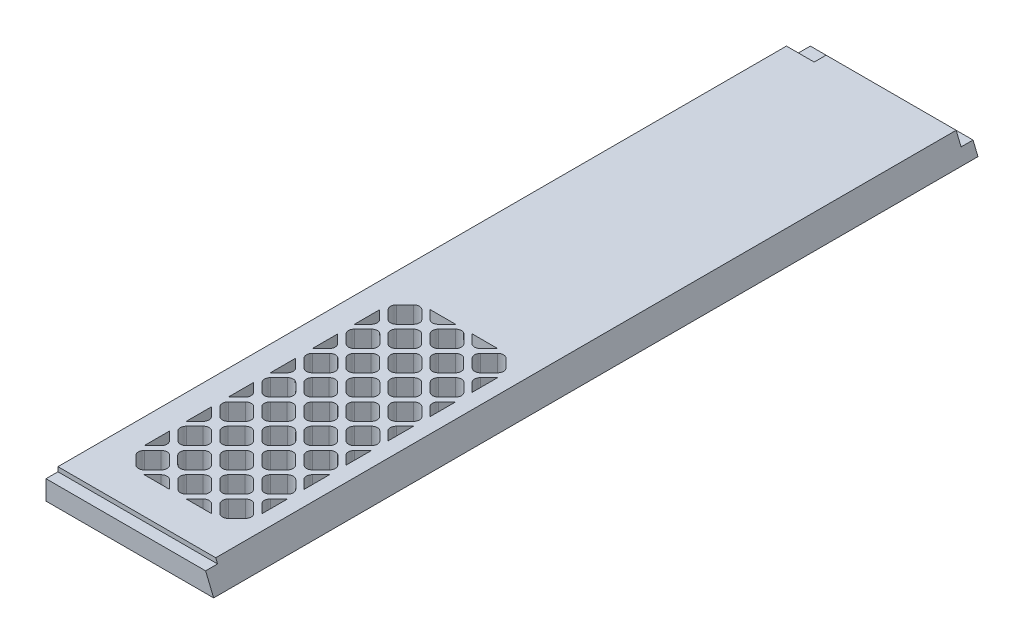
from build123d import *

# Parameters (mm, degrees)
BOSS_EXTRUDE1_DEPTH = 406.4
SKETCH2_W           = 89.154
SKETCH2_H           = 6.35
CUT_EXTRUDE1_DEPTH  = 2.3622
CUT_EXTRUDE3_DEPTH  = 13.7
CUT_EXTRUDE4_DEPTH  = 6.35


with BuildPart() as part:
    # Sketch1 → Boss-Extrude1 (new body)
    with BuildSketch(Plane.XY):
        Polygon((0, 0), (0, 12.7), (83.893487758, 12.7), (89.154, 0), align=None)
    extrude(amount=BOSS_EXTRUDE1_DEPTH)

    # Sketch2 → Cut-Extrude1 (cut)
    with BuildSketch(Plane.XZ.offset(-12.7)):
        with Locations((44.577, 403.225)):
            Rectangle(SKETCH2_W, SKETCH2_H)
    extrude(amount=CUT_EXTRUDE1_DEPTH, mode=Mode.SUBTRACT)

    # Sketch3 → Cut-Extrude3 (cut, through all)
    with BuildSketch(Plane.XZ):
        with BuildLine():
            ThreePointArc((19.97993597, 378.591192091), (22.225, 379.521128061), (24.47006403, 378.591192091))
            Line((24.47006403, 378.591192091), (28.960192091, 374.10106403))
            ThreePointArc((28.960192091, 374.10106403), (29.890128061, 371.856), (28.960192091, 369.61093597))
            Line((28.960192091, 369.61093597), (24.47006403, 365.120807909))
            ThreePointArc((24.47006403, 365.120807909), (22.225, 364.190871939), (19.97993597, 365.120807909))
            Line((19.97993597, 365.120807909), (15.489807909, 369.61093597))
            ThreePointArc((15.489807909, 369.61093597), (14.559871939, 371.856), (15.489807909, 374.10106403))
            Line((15.489807909, 374.10106403), (19.97993597, 378.591192091))
        make_face()
        with BuildLine():
            ThreePointArc((51.312192091, 374.10106403), (52.242128061, 371.856), (51.312192091, 369.61093597))
            Line((51.312192091, 369.61093597), (46.82206403, 365.120807909))
            ThreePointArc((46.82206403, 365.120807909), (44.577, 364.190871939), (42.33193597, 365.120807909))
            Line((42.33193597, 365.120807909), (37.841807909, 369.61093597))
            ThreePointArc((37.841807909, 369.61093597), (36.911871939, 371.856), (37.841807909, 374.10106403))
            Line((37.841807909, 374.10106403), (42.33193597, 378.591192091))
            ThreePointArc((42.33193597, 378.591192091), (44.577, 379.521128061), (46.82206403, 378.591192091))
            Line((46.82206403, 378.591192091), (51.312192091, 374.10106403))
        make_face()
        with BuildLine():
            ThreePointArc((73.664192091, 374.10106403), (74.594128061, 371.856), (73.664192091, 369.61093597))
            Line((73.664192091, 369.61093597), (69.17406403, 365.120807909))
            ThreePointArc((69.17406403, 365.120807909), (66.929, 364.190871939), (64.68393597, 365.120807909))
            Line((64.68393597, 365.120807909), (60.193807909, 369.61093597))
            ThreePointArc((60.193807909, 369.61093597), (59.263871939, 371.856), (60.193807909, 374.10106403))
            Line((60.193807909, 374.10106403), (64.68393597, 378.591192091))
            ThreePointArc((64.68393597, 378.591192091), (66.929, 379.521128061), (69.17406403, 378.591192091))
            Line((69.17406403, 378.591192091), (73.664192091, 374.10106403))
        make_face()
        with BuildLine():
            Line((40.086871939, 380.836256121), (26.616487758, 380.836256121))
            Line((26.616487758, 380.836256121), (31.106615818, 376.346128061))
            ThreePointArc((31.106615818, 376.346128061), (33.351679849, 375.416192091), (35.596743879, 376.346128061))
            Line((35.596743879, 376.346128061), (40.086871939, 380.836256121))
        make_face()
        with BuildLine():
            Line((17.734871939, 362.974384182), (13.244743879, 367.464512242))
            Line((13.244743879, 367.464512242), (13.244743879, 353.994128061))
            Line((13.244743879, 353.994128061), (17.734871939, 358.484256121))
            ThreePointArc((17.734871939, 358.484256121), (18.664807909, 360.729320151), (17.734871939, 362.974384182))
        make_face()
        with BuildLine():
            ThreePointArc((35.596743879, 353.994128061), (33.351679849, 353.064192091), (31.106615818, 353.994128061))
            Line((31.106615818, 353.994128061), (26.616487758, 358.484256121))
            ThreePointArc((26.616487758, 358.484256121), (25.686551788, 360.729320151), (26.616487758, 362.974384182))
            Line((26.616487758, 362.974384182), (31.106615818, 367.464512242))
            ThreePointArc((31.106615818, 367.464512242), (33.351679849, 368.394448212), (35.596743879, 367.464512242))
            Line((35.596743879, 367.464512242), (40.086871939, 362.974384182))
            ThreePointArc((40.086871939, 362.974384182), (41.016807909, 360.729320151), (40.086871939, 358.484256121))
            Line((40.086871939, 358.484256121), (35.596743879, 353.994128061))
        make_face()
        with BuildLine():
            ThreePointArc((57.948743879, 353.994128061), (55.703679849, 353.064192091), (53.458615818, 353.994128061))
            Line((53.458615818, 353.994128061), (48.968487758, 358.484256121))
            ThreePointArc((48.968487758, 358.484256121), (48.038551788, 360.729320151), (48.968487758, 362.974384182))
            Line((48.968487758, 362.974384182), (53.458615818, 367.464512242))
            ThreePointArc((53.458615818, 367.464512242), (55.703679849, 368.394448212), (57.948743879, 367.464512242))
            Line((57.948743879, 367.464512242), (62.438871939, 362.974384182))
            ThreePointArc((62.438871939, 362.974384182), (63.368807909, 360.729320151), (62.438871939, 358.484256121))
            Line((62.438871939, 358.484256121), (57.948743879, 353.994128061))
        make_face()
        with BuildLine():
            Line((75.909256121, 353.89964295), (75.909256121, 367.558997353))
            ThreePointArc((75.909256121, 367.558997353), (75.859427805, 367.51228531), (75.810615818, 367.464512242))
            Line((75.810615818, 367.464512242), (71.320487758, 362.974384182))
            ThreePointArc((71.320487758, 362.974384182), (70.390551788, 360.729320151), (71.320487758, 358.484256121))
            Line((71.320487758, 358.484256121), (75.810615818, 353.994128061))
            ThreePointArc((75.810615818, 353.994128061), (75.859427805, 353.946354993), (75.909256121, 353.89964295))
        make_face()
        with BuildLine():
            ThreePointArc((28.960192091, 351.74906403), (29.890128061, 349.504), (28.960192091, 347.25893597))
            Line((28.960192091, 347.25893597), (24.47006403, 342.768807909))
            ThreePointArc((24.47006403, 342.768807909), (22.225, 341.838871939), (19.97993597, 342.768807909))
            Line((19.97993597, 342.768807909), (15.489807909, 347.25893597))
            ThreePointArc((15.489807909, 347.25893597), (14.559871939, 349.504), (15.489807909, 351.74906403))
            Line((15.489807909, 351.74906403), (19.97993597, 356.239192091))
            ThreePointArc((19.97993597, 356.239192091), (22.225, 357.169128061), (24.47006403, 356.239192091))
            Line((24.47006403, 356.239192091), (28.960192091, 351.74906403))
        make_face()
        with BuildLine():
            ThreePointArc((46.82206403, 342.768807909), (44.577, 341.838871939), (42.33193597, 342.768807909))
            Line((42.33193597, 342.768807909), (37.841807909, 347.25893597))
            ThreePointArc((37.841807909, 347.25893597), (36.911871939, 349.504), (37.841807909, 351.74906403))
            Line((37.841807909, 351.74906403), (42.33193597, 356.239192091))
            ThreePointArc((42.33193597, 356.239192091), (44.577, 357.169128061), (46.82206403, 356.239192091))
            Line((46.82206403, 356.239192091), (51.312192091, 351.74906403))
            ThreePointArc((51.312192091, 351.74906403), (52.242128061, 349.504), (51.312192091, 347.25893597))
            Line((51.312192091, 347.25893597), (46.82206403, 342.768807909))
        make_face()
        with BuildLine():
            ThreePointArc((69.17406403, 342.768807909), (66.929, 341.838871939), (64.68393597, 342.768807909))
            Line((64.68393597, 342.768807909), (60.193807909, 347.25893597))
            ThreePointArc((60.193807909, 347.25893597), (59.263871939, 349.504), (60.193807909, 351.74906403))
            Line((60.193807909, 351.74906403), (64.68393597, 356.239192091))
            ThreePointArc((64.68393597, 356.239192091), (66.929, 357.169128061), (69.17406403, 356.239192091))
            Line((69.17406403, 356.239192091), (73.664192091, 351.74906403))
            ThreePointArc((73.664192091, 351.74906403), (74.594128061, 349.504), (73.664192091, 347.25893597))
            Line((73.664192091, 347.25893597), (69.17406403, 342.768807909))
        make_face()
        with BuildLine():
            Line((75.909256121, 331.54764295), (75.909256121, 345.206997353))
            ThreePointArc((75.909256121, 345.206997353), (75.859427805, 345.16028531), (75.810615818, 345.112512242))
            Line((75.810615818, 345.112512242), (71.320487758, 340.622384182))
            ThreePointArc((71.320487758, 340.622384182), (70.390551788, 338.377320151), (71.320487758, 336.132256121))
            Line((71.320487758, 336.132256121), (75.810615818, 331.642128061))
            ThreePointArc((75.810615818, 331.642128061), (75.859427805, 331.594354993), (75.909256121, 331.54764295))
        make_face()
        with BuildLine():
            ThreePointArc((57.948743879, 331.642128061), (55.703679849, 330.712192091), (53.458615818, 331.642128061))
            Line((53.458615818, 331.642128061), (48.968487758, 336.132256121))
            ThreePointArc((48.968487758, 336.132256121), (48.038551788, 338.377320151), (48.968487758, 340.622384182))
            Line((48.968487758, 340.622384182), (53.458615818, 345.112512242))
            ThreePointArc((53.458615818, 345.112512242), (55.703679849, 346.042448212), (57.948743879, 345.112512242))
            Line((57.948743879, 345.112512242), (62.438871939, 340.622384182))
            ThreePointArc((62.438871939, 340.622384182), (63.368807909, 338.377320151), (62.438871939, 336.132256121))
            Line((62.438871939, 336.132256121), (57.948743879, 331.642128061))
        make_face()
        with BuildLine():
            ThreePointArc((35.596743879, 331.642128061), (33.351679849, 330.712192091), (31.106615818, 331.642128061))
            Line((31.106615818, 331.642128061), (26.616487758, 336.132256121))
            ThreePointArc((26.616487758, 336.132256121), (25.686551788, 338.377320151), (26.616487758, 340.622384182))
            Line((26.616487758, 340.622384182), (31.106615818, 345.112512242))
            ThreePointArc((31.106615818, 345.112512242), (33.351679849, 346.042448212), (35.596743879, 345.112512242))
            Line((35.596743879, 345.112512242), (40.086871939, 340.622384182))
            ThreePointArc((40.086871939, 340.622384182), (41.016807909, 338.377320151), (40.086871939, 336.132256121))
            Line((40.086871939, 336.132256121), (35.596743879, 331.642128061))
        make_face()
        with BuildLine():
            Line((17.734871939, 340.622384182), (13.244743879, 345.112512242))
            Line((13.244743879, 345.112512242), (13.244743879, 331.642128061))
            Line((13.244743879, 331.642128061), (17.734871939, 336.132256121))
            ThreePointArc((17.734871939, 336.132256121), (18.664807909, 338.377320151), (17.734871939, 340.622384182))
        make_face()
        with BuildLine():
            ThreePointArc((28.960192091, 329.39706403), (29.890128061, 327.152), (28.960192091, 324.90693597))
            Line((28.960192091, 324.90693597), (24.47006403, 320.416807909))
            ThreePointArc((24.47006403, 320.416807909), (22.225, 319.486871939), (19.97993597, 320.416807909))
            Line((19.97993597, 320.416807909), (15.489807909, 324.90693597))
            ThreePointArc((15.489807909, 324.90693597), (14.559871939, 327.152), (15.489807909, 329.39706403))
            Line((15.489807909, 329.39706403), (19.97993597, 333.887192091))
            ThreePointArc((19.97993597, 333.887192091), (22.225, 334.817128061), (24.47006403, 333.887192091))
            Line((24.47006403, 333.887192091), (28.960192091, 329.39706403))
        make_face()
        with BuildLine():
            ThreePointArc((46.82206403, 320.416807909), (44.577, 319.486871939), (42.33193597, 320.416807909))
            Line((42.33193597, 320.416807909), (37.841807909, 324.90693597))
            ThreePointArc((37.841807909, 324.90693597), (36.911871939, 327.152), (37.841807909, 329.39706403))
            Line((37.841807909, 329.39706403), (42.33193597, 333.887192091))
            ThreePointArc((42.33193597, 333.887192091), (44.577, 334.817128061), (46.82206403, 333.887192091))
            Line((46.82206403, 333.887192091), (51.312192091, 329.39706403))
            ThreePointArc((51.312192091, 329.39706403), (52.242128061, 327.152), (51.312192091, 324.90693597))
            Line((51.312192091, 324.90693597), (46.82206403, 320.416807909))
        make_face()
        with BuildLine():
            ThreePointArc((69.17406403, 320.416807909), (66.929, 319.486871939), (64.68393597, 320.416807909))
            Line((64.68393597, 320.416807909), (60.193807909, 324.90693597))
            ThreePointArc((60.193807909, 324.90693597), (59.263871939, 327.152), (60.193807909, 329.39706403))
            Line((60.193807909, 329.39706403), (64.68393597, 333.887192091))
            ThreePointArc((64.68393597, 333.887192091), (66.929, 334.817128061), (69.17406403, 333.887192091))
            Line((69.17406403, 333.887192091), (73.664192091, 329.39706403))
            ThreePointArc((73.664192091, 329.39706403), (74.594128061, 327.152), (73.664192091, 324.90693597))
            Line((73.664192091, 324.90693597), (69.17406403, 320.416807909))
        make_face()
        with BuildLine():
            ThreePointArc((57.948743879, 309.290128061), (55.703679849, 308.360192091), (53.458615818, 309.290128061))
            Line((53.458615818, 309.290128061), (48.968487758, 313.780256121))
            ThreePointArc((48.968487758, 313.780256121), (48.038551788, 316.025320151), (48.968487758, 318.270384182))
            Line((48.968487758, 318.270384182), (53.458615818, 322.760512242))
            ThreePointArc((53.458615818, 322.760512242), (55.703679849, 323.690448212), (57.948743879, 322.760512242))
            Line((57.948743879, 322.760512242), (62.438871939, 318.270384182))
            ThreePointArc((62.438871939, 318.270384182), (63.368807909, 316.025320151), (62.438871939, 313.780256121))
            Line((62.438871939, 313.780256121), (57.948743879, 309.290128061))
        make_face()
        with BuildLine():
            Line((75.909256121, 309.19564295), (75.909256121, 322.854997353))
            ThreePointArc((75.909256121, 322.854997353), (75.859427805, 322.80828531), (75.810615818, 322.760512242))
            Line((75.810615818, 322.760512242), (71.320487758, 318.270384182))
            ThreePointArc((71.320487758, 318.270384182), (70.390551788, 316.025320151), (71.320487758, 313.780256121))
            Line((71.320487758, 313.780256121), (75.810615818, 309.290128061))
            ThreePointArc((75.810615818, 309.290128061), (75.859427805, 309.242354993), (75.909256121, 309.19564295))
        make_face()
        with BuildLine():
            Line((62.438871939, 380.836256121), (48.968487758, 380.836256121))
            Line((48.968487758, 380.836256121), (53.458615818, 376.346128061))
            ThreePointArc((53.458615818, 376.346128061), (55.703679849, 375.416192091), (57.948743879, 376.346128061))
            Line((57.948743879, 376.346128061), (62.438871939, 380.836256121))
        make_face()
        with BuildLine():
            ThreePointArc((35.596743879, 309.290128061), (33.351679849, 308.360192091), (31.106615818, 309.290128061))
            Line((31.106615818, 309.290128061), (26.616487758, 313.780256121))
            ThreePointArc((26.616487758, 313.780256121), (25.686551788, 316.025320151), (26.616487758, 318.270384182))
            Line((26.616487758, 318.270384182), (31.106615818, 322.760512242))
            ThreePointArc((31.106615818, 322.760512242), (33.351679849, 323.690448212), (35.596743879, 322.760512242))
            Line((35.596743879, 322.760512242), (40.086871939, 318.270384182))
            ThreePointArc((40.086871939, 318.270384182), (41.016807909, 316.025320151), (40.086871939, 313.780256121))
            Line((40.086871939, 313.780256121), (35.596743879, 309.290128061))
        make_face()
        with BuildLine():
            Line((17.734871939, 318.270384182), (13.244743879, 322.760512242))
            Line((13.244743879, 322.760512242), (13.244743879, 309.290128061))
            Line((13.244743879, 309.290128061), (17.734871939, 313.780256121))
            ThreePointArc((17.734871939, 313.780256121), (18.664807909, 316.025320151), (17.734871939, 318.270384182))
        make_face()
        with BuildLine():
            ThreePointArc((28.960192091, 307.04506403), (29.890128061, 304.8), (28.960192091, 302.55493597))
            Line((28.960192091, 302.55493597), (24.47006403, 298.064807909))
            ThreePointArc((24.47006403, 298.064807909), (22.225, 297.134871939), (19.97993597, 298.064807909))
            Line((19.97993597, 298.064807909), (15.489807909, 302.55493597))
            ThreePointArc((15.489807909, 302.55493597), (14.559871939, 304.8), (15.489807909, 307.04506403))
            Line((15.489807909, 307.04506403), (19.97993597, 311.535192091))
            ThreePointArc((19.97993597, 311.535192091), (22.225, 312.465128061), (24.47006403, 311.535192091))
            Line((24.47006403, 311.535192091), (28.960192091, 307.04506403))
        make_face()
        with BuildLine():
            ThreePointArc((46.82206403, 298.064807909), (44.577, 297.134871939), (42.33193597, 298.064807909))
            Line((42.33193597, 298.064807909), (37.841807909, 302.55493597))
            ThreePointArc((37.841807909, 302.55493597), (36.911871939, 304.8), (37.841807909, 307.04506403))
            Line((37.841807909, 307.04506403), (42.33193597, 311.535192091))
            ThreePointArc((42.33193597, 311.535192091), (44.577, 312.465128061), (46.82206403, 311.535192091))
            Line((46.82206403, 311.535192091), (51.312192091, 307.04506403))
            ThreePointArc((51.312192091, 307.04506403), (52.242128061, 304.8), (51.312192091, 302.55493597))
            Line((51.312192091, 302.55493597), (46.82206403, 298.064807909))
        make_face()
        with BuildLine():
            ThreePointArc((69.17406403, 298.064807909), (66.929, 297.134871939), (64.68393597, 298.064807909))
            Line((64.68393597, 298.064807909), (60.193807909, 302.55493597))
            ThreePointArc((60.193807909, 302.55493597), (59.263871939, 304.8), (60.193807909, 307.04506403))
            Line((60.193807909, 307.04506403), (64.68393597, 311.535192091))
            ThreePointArc((64.68393597, 311.535192091), (66.929, 312.465128061), (69.17406403, 311.535192091))
            Line((69.17406403, 311.535192091), (73.664192091, 307.04506403))
            ThreePointArc((73.664192091, 307.04506403), (74.594128061, 304.8), (73.664192091, 302.55493597))
            Line((73.664192091, 302.55493597), (69.17406403, 298.064807909))
        make_face()
        with BuildLine():
            Line((17.734871939, 295.918384182), (13.244743879, 300.408512242))
            Line((13.244743879, 300.408512242), (13.244743879, 286.938128061))
            Line((13.244743879, 286.938128061), (17.734871939, 291.428256121))
            ThreePointArc((17.734871939, 291.428256121), (18.664807909, 293.673320151), (17.734871939, 295.918384182))
        make_face()
        with BuildLine():
            ThreePointArc((28.960192091, 284.69306403), (29.890128061, 282.448), (28.960192091, 280.20293597))
            Line((28.960192091, 280.20293597), (24.47006403, 275.712807909))
            ThreePointArc((24.47006403, 275.712807909), (22.225, 274.782871939), (19.97993597, 275.712807909))
            Line((19.97993597, 275.712807909), (15.489807909, 280.20293597))
            ThreePointArc((15.489807909, 280.20293597), (14.559871939, 282.448), (15.489807909, 284.69306403))
            Line((15.489807909, 284.69306403), (19.97993597, 289.183192091))
            ThreePointArc((19.97993597, 289.183192091), (22.225, 290.113128061), (24.47006403, 289.183192091))
            Line((24.47006403, 289.183192091), (28.960192091, 284.69306403))
        make_face()
        with BuildLine():
            ThreePointArc((35.596743879, 286.938128061), (33.351679849, 286.008192091), (31.106615818, 286.938128061))
            Line((31.106615818, 286.938128061), (26.616487758, 291.428256121))
            ThreePointArc((26.616487758, 291.428256121), (25.686551788, 293.673320151), (26.616487758, 295.918384182))
            Line((26.616487758, 295.918384182), (31.106615818, 300.408512242))
            ThreePointArc((31.106615818, 300.408512242), (33.351679849, 301.338448212), (35.596743879, 300.408512242))
            Line((35.596743879, 300.408512242), (40.086871939, 295.918384182))
            ThreePointArc((40.086871939, 295.918384182), (41.016807909, 293.673320151), (40.086871939, 291.428256121))
            Line((40.086871939, 291.428256121), (35.596743879, 286.938128061))
        make_face()
        with BuildLine():
            ThreePointArc((46.82206403, 275.712807909), (44.577, 274.782871939), (42.33193597, 275.712807909))
            Line((42.33193597, 275.712807909), (37.841807909, 280.20293597))
            ThreePointArc((37.841807909, 280.20293597), (36.911871939, 282.448), (37.841807909, 284.69306403))
            Line((37.841807909, 284.69306403), (42.33193597, 289.183192091))
            ThreePointArc((42.33193597, 289.183192091), (44.577, 290.113128061), (46.82206403, 289.183192091))
            Line((46.82206403, 289.183192091), (51.312192091, 284.69306403))
            ThreePointArc((51.312192091, 284.69306403), (52.242128061, 282.448), (51.312192091, 280.20293597))
            Line((51.312192091, 280.20293597), (46.82206403, 275.712807909))
        make_face()
        with BuildLine():
            ThreePointArc((57.948743879, 286.938128061), (55.703679849, 286.008192091), (53.458615818, 286.938128061))
            Line((53.458615818, 286.938128061), (48.968487758, 291.428256121))
            ThreePointArc((48.968487758, 291.428256121), (48.038551788, 293.673320151), (48.968487758, 295.918384182))
            Line((48.968487758, 295.918384182), (53.458615818, 300.408512242))
            ThreePointArc((53.458615818, 300.408512242), (55.703679849, 301.338448212), (57.948743879, 300.408512242))
            Line((57.948743879, 300.408512242), (62.438871939, 295.918384182))
            ThreePointArc((62.438871939, 295.918384182), (63.368807909, 293.673320151), (62.438871939, 291.428256121))
            Line((62.438871939, 291.428256121), (57.948743879, 286.938128061))
        make_face()
        with BuildLine():
            Line((75.909256121, 286.84364295), (75.909256121, 300.502997353))
            ThreePointArc((75.909256121, 300.502997353), (75.859427805, 300.45628531), (75.810615818, 300.408512242))
            Line((75.810615818, 300.408512242), (71.320487758, 295.918384182))
            ThreePointArc((71.320487758, 295.918384182), (70.390551788, 293.673320151), (71.320487758, 291.428256121))
            Line((71.320487758, 291.428256121), (75.810615818, 286.938128061))
            ThreePointArc((75.810615818, 286.938128061), (75.859427805, 286.890354993), (75.909256121, 286.84364295))
        make_face()
        with BuildLine():
            ThreePointArc((69.17406403, 275.712807909), (66.929, 274.782871939), (64.68393597, 275.712807909))
            Line((64.68393597, 275.712807909), (60.193807909, 280.20293597))
            ThreePointArc((60.193807909, 280.20293597), (59.263871939, 282.448), (60.193807909, 284.69306403))
            Line((60.193807909, 284.69306403), (64.68393597, 289.183192091))
            ThreePointArc((64.68393597, 289.183192091), (66.929, 290.113128061), (69.17406403, 289.183192091))
            Line((69.17406403, 289.183192091), (73.664192091, 284.69306403))
            ThreePointArc((73.664192091, 284.69306403), (74.594128061, 282.448), (73.664192091, 280.20293597))
            Line((73.664192091, 280.20293597), (69.17406403, 275.712807909))
        make_face()
        with BuildLine():
            Line((17.734871939, 273.566384182), (13.244743879, 278.056512242))
            Line((13.244743879, 278.056512242), (13.244743879, 264.586128061))
            Line((13.244743879, 264.586128061), (17.734871939, 269.076256121))
            ThreePointArc((17.734871939, 269.076256121), (18.664807909, 271.321320151), (17.734871939, 273.566384182))
        make_face()
        with BuildLine():
            ThreePointArc((35.596743879, 264.586128061), (33.351679849, 263.656192091), (31.106615818, 264.586128061))
            Line((31.106615818, 264.586128061), (26.616487758, 269.076256121))
            ThreePointArc((26.616487758, 269.076256121), (25.686551788, 271.321320151), (26.616487758, 273.566384182))
            Line((26.616487758, 273.566384182), (31.106615818, 278.056512242))
            ThreePointArc((31.106615818, 278.056512242), (33.351679849, 278.986448212), (35.596743879, 278.056512242))
            Line((35.596743879, 278.056512242), (40.086871939, 273.566384182))
            ThreePointArc((40.086871939, 273.566384182), (41.016807909, 271.321320151), (40.086871939, 269.076256121))
            Line((40.086871939, 269.076256121), (35.596743879, 264.586128061))
        make_face()
        with BuildLine():
            ThreePointArc((57.948743879, 264.586128061), (55.703679849, 263.656192091), (53.458615818, 264.586128061))
            Line((53.458615818, 264.586128061), (48.968487758, 269.076256121))
            ThreePointArc((48.968487758, 269.076256121), (48.038551788, 271.321320151), (48.968487758, 273.566384182))
            Line((48.968487758, 273.566384182), (53.458615818, 278.056512242))
            ThreePointArc((53.458615818, 278.056512242), (55.703679849, 278.986448212), (57.948743879, 278.056512242))
            Line((57.948743879, 278.056512242), (62.438871939, 273.566384182))
            ThreePointArc((62.438871939, 273.566384182), (63.368807909, 271.321320151), (62.438871939, 269.076256121))
            Line((62.438871939, 269.076256121), (57.948743879, 264.586128061))
        make_face()
        with BuildLine():
            Line((75.909256121, 264.49164295), (75.909256121, 278.150997353))
            ThreePointArc((75.909256121, 278.150997353), (75.859427805, 278.10428531), (75.810615818, 278.056512242))
            Line((75.810615818, 278.056512242), (71.320487758, 273.566384182))
            ThreePointArc((71.320487758, 273.566384182), (70.390551788, 271.321320151), (71.320487758, 269.076256121))
            Line((71.320487758, 269.076256121), (75.810615818, 264.586128061))
            ThreePointArc((75.810615818, 264.586128061), (75.859427805, 264.538354993), (75.909256121, 264.49164295))
        make_face()
        with BuildLine():
            ThreePointArc((69.17406403, 253.360807909), (66.929, 252.430871939), (64.68393597, 253.360807909))
            Line((64.68393597, 253.360807909), (60.193807909, 257.85093597))
            ThreePointArc((60.193807909, 257.85093597), (59.263871939, 260.096), (60.193807909, 262.34106403))
            Line((60.193807909, 262.34106403), (64.68393597, 266.831192091))
            ThreePointArc((64.68393597, 266.831192091), (66.929, 267.761128061), (69.17406403, 266.831192091))
            Line((69.17406403, 266.831192091), (73.664192091, 262.34106403))
            ThreePointArc((73.664192091, 262.34106403), (74.594128061, 260.096), (73.664192091, 257.85093597))
            Line((73.664192091, 257.85093597), (69.17406403, 253.360807909))
        make_face()
        with BuildLine():
            ThreePointArc((46.82206403, 253.360807909), (44.577, 252.430871939), (42.33193597, 253.360807909))
            Line((42.33193597, 253.360807909), (37.841807909, 257.85093597))
            ThreePointArc((37.841807909, 257.85093597), (36.911871939, 260.096), (37.841807909, 262.34106403))
            Line((37.841807909, 262.34106403), (42.33193597, 266.831192091))
            ThreePointArc((42.33193597, 266.831192091), (44.577, 267.761128061), (46.82206403, 266.831192091))
            Line((46.82206403, 266.831192091), (51.312192091, 262.34106403))
            ThreePointArc((51.312192091, 262.34106403), (52.242128061, 260.096), (51.312192091, 257.85093597))
            Line((51.312192091, 257.85093597), (46.82206403, 253.360807909))
        make_face()
        with BuildLine():
            ThreePointArc((28.960192091, 262.34106403), (29.890128061, 260.096), (28.960192091, 257.85093597))
            Line((28.960192091, 257.85093597), (24.47006403, 253.360807909))
            ThreePointArc((24.47006403, 253.360807909), (22.225, 252.430871939), (19.97993597, 253.360807909))
            Line((19.97993597, 253.360807909), (15.489807909, 257.85093597))
            ThreePointArc((15.489807909, 257.85093597), (14.559871939, 260.096), (15.489807909, 262.34106403))
            Line((15.489807909, 262.34106403), (19.97993597, 266.831192091))
            ThreePointArc((19.97993597, 266.831192091), (22.225, 267.761128061), (24.47006403, 266.831192091))
            Line((24.47006403, 266.831192091), (28.960192091, 262.34106403))
        make_face()
        with BuildLine():
            Line((17.734871939, 251.214384182), (13.244743879, 255.704512242))
            Line((13.244743879, 255.704512242), (13.244743879, 242.234128061))
            Line((13.244743879, 242.234128061), (17.734871939, 246.724256121))
            ThreePointArc((17.734871939, 246.724256121), (18.664807909, 248.969320151), (17.734871939, 251.214384182))
        make_face()
        with BuildLine():
            ThreePointArc((28.960192091, 239.98906403), (29.890128061, 237.744), (28.960192091, 235.49893597))
            Line((28.960192091, 235.49893597), (24.47006403, 231.008807909))
            ThreePointArc((24.47006403, 231.008807909), (22.225, 230.078871939), (19.97993597, 231.008807909))
            Line((19.97993597, 231.008807909), (15.489807909, 235.49893597))
            ThreePointArc((15.489807909, 235.49893597), (14.559871939, 237.744), (15.489807909, 239.98906403))
            Line((15.489807909, 239.98906403), (19.97993597, 244.479192091))
            ThreePointArc((19.97993597, 244.479192091), (22.225, 245.409128061), (24.47006403, 244.479192091))
            Line((24.47006403, 244.479192091), (28.960192091, 239.98906403))
        make_face()
        with BuildLine():
            ThreePointArc((35.596743879, 242.234128061), (33.351679849, 241.304192091), (31.106615818, 242.234128061))
            Line((31.106615818, 242.234128061), (26.616487758, 246.724256121))
            ThreePointArc((26.616487758, 246.724256121), (25.686551788, 248.969320151), (26.616487758, 251.214384182))
            Line((26.616487758, 251.214384182), (31.106615818, 255.704512242))
            ThreePointArc((31.106615818, 255.704512242), (33.351679849, 256.634448212), (35.596743879, 255.704512242))
            Line((35.596743879, 255.704512242), (40.086871939, 251.214384182))
            ThreePointArc((40.086871939, 251.214384182), (41.016807909, 248.969320151), (40.086871939, 246.724256121))
            Line((40.086871939, 246.724256121), (35.596743879, 242.234128061))
        make_face()
        with BuildLine():
            ThreePointArc((26.616487758, 228.862384182), (26.56871469, 228.813572195), (26.522002647, 228.763743879))
            Line((26.522002647, 228.763743879), (40.18135705, 228.763743879))
            ThreePointArc((40.18135705, 228.763743879), (40.134645007, 228.813572195), (40.086871939, 228.862384182))
            Line((40.086871939, 228.862384182), (35.596743879, 233.352512242))
            ThreePointArc((35.596743879, 233.352512242), (33.351679849, 234.282448212), (31.106615818, 233.352512242))
            Line((31.106615818, 233.352512242), (26.616487758, 228.862384182))
        make_face()
        with BuildLine():
            ThreePointArc((46.82206403, 231.008807909), (44.577, 230.078871939), (42.33193597, 231.008807909))
            Line((42.33193597, 231.008807909), (37.841807909, 235.49893597))
            ThreePointArc((37.841807909, 235.49893597), (36.911871939, 237.744), (37.841807909, 239.98906403))
            Line((37.841807909, 239.98906403), (42.33193597, 244.479192091))
            ThreePointArc((42.33193597, 244.479192091), (44.577, 245.409128061), (46.82206403, 244.479192091))
            Line((46.82206403, 244.479192091), (51.312192091, 239.98906403))
            ThreePointArc((51.312192091, 239.98906403), (52.242128061, 237.744), (51.312192091, 235.49893597))
            Line((51.312192091, 235.49893597), (46.82206403, 231.008807909))
        make_face()
        with BuildLine():
            ThreePointArc((57.948743879, 242.234128061), (55.703679849, 241.304192091), (53.458615818, 242.234128061))
            Line((53.458615818, 242.234128061), (48.968487758, 246.724256121))
            ThreePointArc((48.968487758, 246.724256121), (48.038551788, 248.969320151), (48.968487758, 251.214384182))
            Line((48.968487758, 251.214384182), (53.458615818, 255.704512242))
            ThreePointArc((53.458615818, 255.704512242), (55.703679849, 256.634448212), (57.948743879, 255.704512242))
            Line((57.948743879, 255.704512242), (62.438871939, 251.214384182))
            ThreePointArc((62.438871939, 251.214384182), (63.368807909, 248.969320151), (62.438871939, 246.724256121))
            Line((62.438871939, 246.724256121), (57.948743879, 242.234128061))
        make_face()
        with BuildLine():
            Line((75.909256121, 242.13964295), (75.909256121, 255.798997353))
            ThreePointArc((75.909256121, 255.798997353), (75.859427805, 255.75228531), (75.810615818, 255.704512242))
            Line((75.810615818, 255.704512242), (71.320487758, 251.214384182))
            ThreePointArc((71.320487758, 251.214384182), (70.390551788, 248.969320151), (71.320487758, 246.724256121))
            Line((71.320487758, 246.724256121), (75.810615818, 242.234128061))
            ThreePointArc((75.810615818, 242.234128061), (75.859427805, 242.186354993), (75.909256121, 242.13964295))
        make_face()
        with BuildLine():
            ThreePointArc((69.17406403, 231.008807909), (66.929, 230.078871939), (64.68393597, 231.008807909))
            Line((64.68393597, 231.008807909), (60.193807909, 235.49893597))
            ThreePointArc((60.193807909, 235.49893597), (59.263871939, 237.744), (60.193807909, 239.98906403))
            Line((60.193807909, 239.98906403), (64.68393597, 244.479192091))
            ThreePointArc((64.68393597, 244.479192091), (66.929, 245.409128061), (69.17406403, 244.479192091))
            Line((69.17406403, 244.479192091), (73.664192091, 239.98906403))
            ThreePointArc((73.664192091, 239.98906403), (74.594128061, 237.744), (73.664192091, 235.49893597))
            Line((73.664192091, 235.49893597), (69.17406403, 231.008807909))
        make_face()
        with BuildLine():
            ThreePointArc((48.968487758, 228.862384182), (48.92071469, 228.813572195), (48.874002647, 228.763743879))
            Line((48.874002647, 228.763743879), (62.53335705, 228.763743879))
            ThreePointArc((62.53335705, 228.763743879), (62.486645007, 228.813572195), (62.438871939, 228.862384182))
            Line((62.438871939, 228.862384182), (57.948743879, 233.352512242))
            ThreePointArc((57.948743879, 233.352512242), (55.703679849, 234.282448212), (53.458615818, 233.352512242))
            Line((53.458615818, 233.352512242), (48.968487758, 228.862384182))
        make_face()
    extrude(amount=-CUT_EXTRUDE3_DEPTH, mode=Mode.SUBTRACT)

    # Sketch4 → Cut-Extrude4 (cut)
    with BuildSketch(Plane(origin=(0, 12.7, 0), x_dir=(1, 0, 0), z_dir=(0, 1, 0))):
        Polygon((126.761956767, -6.35), (14.743545349, -6.35), (14.743545349, -12.7), (0, -12.7), (0, -6.35), (0, 0), (126.761956767, 0), align=None)
    extrude(amount=-CUT_EXTRUDE4_DEPTH, mode=Mode.SUBTRACT)


solid = part.part
